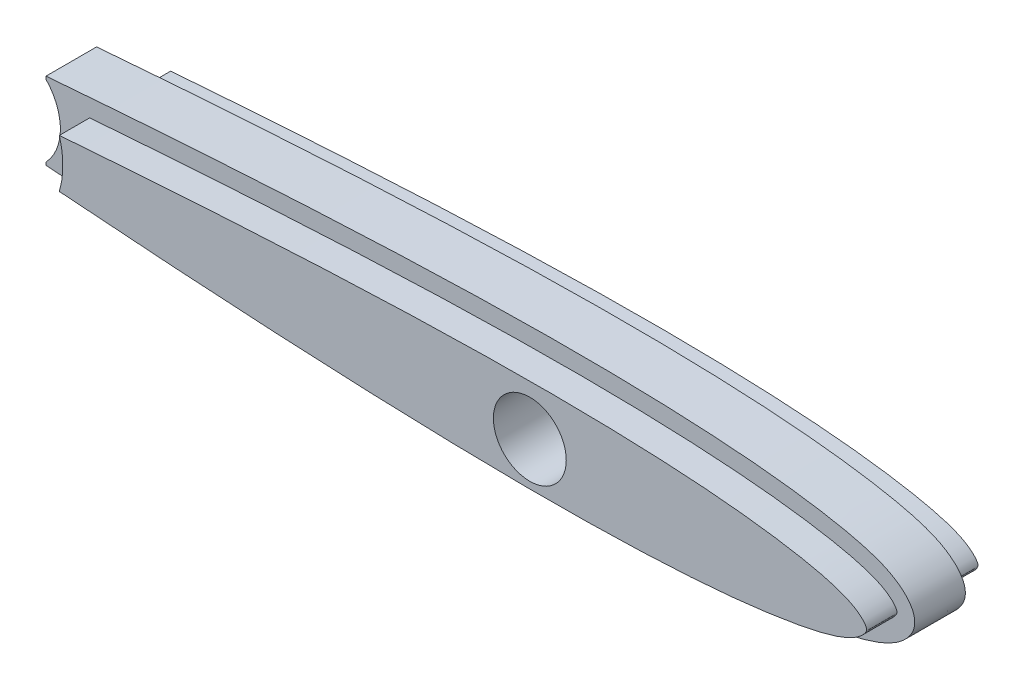
from build123d import *

# Parameters (mm, degrees)
BOSS_EXTRUDE1_DEPTH = 5
SKETCH2_R           = 3.6
CUT_EXTRUDE1_DEPTH  = 5
SKETCH3_R           = 3.6
BOSS_EXTRUDE2_DEPTH = 3
SKETCH4_R           = 3.6
BOSS_EXTRUDE3_DEPTH = 3
CUT_EXTRUDE2_DEPTH  = 3
CUT_EXTRUDE3_DEPTH  = 3


with BuildPart() as part:
    # Sketch1 → Boss-Extrude1 (new body)
    with BuildSketch(Plane.XY):
        with BuildLine():
            Line((-706.793809994, 2.250411623), (-706.793809994, 1.97147251))
            ThreePointArc((-706.793809994, 1.97147251), (-705.375068537, -1.563521785), (-706.793809994, -5.098516081))
            Line((-706.793809994, -5.098516081), (-706.793809994, -5.380220718))
            add(Edge.make_bspline(
                [(-706.793809994, -5.380220718), (-704.176375439, -5.591973248), (-696.788271806, -6.160981291), (-687.004943636, -6.814750309), (-677.443429578, -7.328465039), (-670.265581518, -7.637849476), (-663.080178273, -7.856949826), (-655.886290791, -7.960144603), (-649.882283211, -7.915795095), (-645.073657094, -7.776750842), (-641.466136989, -7.609887873), (-637.854648483, -7.365546758), (-634.840780847, -7.078684435), (-632.429284229, -6.778677485), (-630.622695626, -6.514858819), (-628.812307662, -6.202098358), (-627.300302349, -5.887519285), (-626.075324578, -5.577261081), (-625.144738566, -5.299811117), (-624.201783041, -4.957795864), (-623.396379776, -4.581537473), (-622.748324583, -4.189477017), (-622.264536531, -3.833178944), (-621.888398496, -3.490996777), (-621.573666417, -3.139905403), (-621.335269439, -2.804387975), (-621.152117781, -2.470444907), (-621.013752956, -2.062687894), (-620.948588409, -1.666438774), (-620.978356512, -1.21846251), (-621.102747046, -0.769863534), (-621.289809051, -0.398734203), (-621.521029667, -0.056164767), (-621.841717048, 0.316577074), (-622.213712109, 0.661285055), (-622.697054763, 1.025995289), (-623.34452358, 1.42498987), (-624.150977835, 1.807769279), (-625.095134852, 2.154209602), (-626.026268782, 2.434457764), (-626.945529144, 2.669327648), (-628.160182101, 2.940961031), (-629.669864195, 3.22796374), (-631.478046966, 3.515544636), (-633.887915069, 3.842279402), (-636.903553501, 4.156872173), (-640.515254098, 4.42458971), (-644.124028039, 4.609745533), (-647.73159652, 4.729751391), (-652.534840565, 4.817654121), (-658.5377679, 4.807713582), (-665.728070005, 4.659067049), (-672.910308043, 4.404167014), (-680.085871056, 4.065223292), (-689.644295843, 3.519258278), (-698.545185009, 2.901350773), (-705.054875216, 2.391074048), (-706.793809994, 2.250411623)],
                knots=[0.161071555, 0.161071555, 0.161071555, 0.161071555, 0.197140461, 0.262860095, 0.295719912, 0.328579729, 0.361439545, 0.394299362, 0.427159179, 0.443589088, 0.460018996, 0.476448904, 0.492878813, 0.501093767, 0.509308721, 0.517523675, 0.52573863, 0.529846107, 0.533953584, 0.538061061, 0.542168538, 0.544222277, 0.546276015, 0.548329754, 0.549356623, 0.550383492, 0.551410361, 0.551923796, 0.552437231, 0.552950665, 0.5534641, 0.554490969, 0.555517839, 0.556544708, 0.558598446, 0.560652185, 0.562705924, 0.566813401, 0.570920878, 0.575028355, 0.579135832, 0.583243309, 0.591458263, 0.599673217, 0.607888172, 0.62431808, 0.640747988, 0.657177897, 0.673607805, 0.690037714, 0.722897531, 0.755757347, 0.788617164, 0.821476981, 0.854336798, 0.920056432, 0.944017709, 0.944017709, 0.944017709, 0.944017709], degree=3))
        make_face()
    extrude(amount=BOSS_EXTRUDE1_DEPTH)

    # Sketch2 → Cut-Extrude1 (cut)
    with BuildSketch(Plane(origin=(0, 0, 0), x_dir=(-1, 0, 0), z_dir=(0, 0, -1))):
        with Locations((655.992889877, -1.919458309)):
            Circle(SKETCH2_R)
    extrude(amount=-CUT_EXTRUDE1_DEPTH, mode=Mode.SUBTRACT)

    # Sketch3 → Boss-Extrude2 (add)
    with BuildSketch(Plane.XY.offset(5)):
        with BuildLine():
            ThreePointArc((-702.8119034, -4.189841251), (-702.375068622, -1.564694249), (-702.811144658, 1.060578898))
            add(Edge.make_bspline(
                [(-702.8119034, -4.189841251), (-700.917313824, -4.336241444), (-696.793783217, -4.643411612), (-690.360255168, -5.085057096), (-683.472099639, -5.505971596), (-676.464013183, -5.873438985), (-669.455701438, -6.165615313), (-663.668912094, -6.334400701), (-659.129505656, -6.411939523), (-655.827098123, -6.439457694), (-652.612824651, -6.435613741), (-649.500432858, -6.394237419), (-646.503492978, -6.321608231), (-643.635086194, -6.211922431), (-640.907267874, -6.069173931), (-638.331358127, -5.890035138), (-635.918279427, -5.677537233), (-633.679144814, -5.429819661), (-631.623287424, -5.151604924), (-629.758745754, -4.850065184), (-628.093285087, -4.52655103), (-626.632315737, -4.182183625), (-625.382756266, -3.805365702), (-624.347318876, -3.389117853), (-623.535477719, -2.929845627), (-622.951664887, -2.450264066), (-622.587069704, -2.010708523), (-622.411159705, -1.564660699), (-622.587069704, -1.118612875), (-622.951664887, -0.679057332), (-623.535477719, -0.199475771), (-624.347318876, 0.259796455), (-625.382756266, 0.676044303), (-626.632315737, 1.052862227), (-628.093285087, 1.397229632), (-629.758745754, 1.720743786), (-631.623287424, 2.022283526), (-633.679144814, 2.300498263), (-635.918279427, 2.548215835), (-638.331358127, 2.76071374), (-640.907267874, 2.939852533), (-643.635086194, 3.082601032), (-646.503492978, 3.192286833), (-649.500432858, 3.264916021), (-652.612824651, 3.306292343), (-655.827098123, 3.310136295), (-659.129505656, 3.282618125), (-663.668912094, 3.205079304), (-669.455701437, 3.03629391), (-676.464013186, 2.744117603), (-683.472099631, 2.376650136), (-690.360255198, 1.955735922), (-696.793530026, 1.514106834), (-700.916808032, 1.20695911), (-702.811144658, 1.060578898)],
                knots=[0.127353429, 0.127353429, 0.127353429, 0.127353429, 0.153490017, 0.184226953, 0.216050302, 0.248408155, 0.280749827, 0.312527151, 0.328032777, 0.343195028, 0.357950764, 0.37224227, 0.386006959, 0.3991829, 0.411723018, 0.423576276, 0.434696708, 0.445039635, 0.454559181, 0.463228705, 0.471014913, 0.477890529, 0.483865645, 0.488951694, 0.493207386, 0.496651844, 0.499261497, 0.501068994, 0.502876492, 0.505486145, 0.508930603, 0.513186294, 0.518272343, 0.524247459, 0.531123075, 0.538909284, 0.547578808, 0.557098354, 0.56744128, 0.578561712, 0.59041497, 0.602955088, 0.61613103, 0.629895718, 0.644187224, 0.658942961, 0.674105212, 0.689610838, 0.721388161, 0.753729833, 0.786087687, 0.817911036, 0.848647972, 0.874781071, 0.874781071, 0.874781071, 0.874781071], degree=3))
        make_face()
        with Locations(Location((-655.992889877, -1.919458309, 0), (0, 0, 180))):
            Circle(SKETCH3_R, mode=Mode.SUBTRACT)
    extrude(amount=BOSS_EXTRUDE2_DEPTH)

    # Sketch4 → Boss-Extrude3 (add)
    with BuildSketch(Plane(origin=(0, 0, 0), x_dir=(-1, 0, 0), z_dir=(0, 0, -1))):
        with BuildLine():
            ThreePointArc((702.811144658, 1.060578898), (702.375068622, -1.564694249), (702.8119034, -4.189841251))
            add(Edge.make_bspline(
                [(702.811144658, 1.060578898), (700.916808032, 1.20695911), (696.793530026, 1.514106834), (690.360255198, 1.955735922), (683.472099631, 2.376650136), (676.464013186, 2.744117603), (669.455701437, 3.03629391), (663.668912094, 3.205079304), (659.129505656, 3.282618125), (655.827098123, 3.310136295), (652.612824651, 3.306292343), (649.500432858, 3.264916021), (646.503492978, 3.192286833), (643.635086194, 3.082601032), (640.907267874, 2.939852533), (638.331358127, 2.76071374), (635.918279427, 2.548215835), (633.679144814, 2.300498263), (631.623287424, 2.022283526), (629.758745754, 1.720743786), (628.093285087, 1.397229632), (626.632315737, 1.052862227), (625.382756266, 0.676044303), (624.347318876, 0.259796455), (623.535477719, -0.199475771), (622.951664887, -0.679057332), (622.587069704, -1.118612875), (622.411159705, -1.564660699), (622.587069704, -2.010708523), (622.951664887, -2.450264066), (623.535477719, -2.929845627), (624.347318876, -3.389117853), (625.382756266, -3.805365702), (626.632315737, -4.182183625), (628.093285087, -4.52655103), (629.758745754, -4.850065184), (631.623287424, -5.151604924), (633.679144814, -5.429819661), (635.918279427, -5.677537233), (638.331358127, -5.890035138), (640.907267874, -6.069173931), (643.635086194, -6.211922431), (646.503492978, -6.321608231), (649.500432858, -6.394237419), (652.612824651, -6.435613741), (655.827098123, -6.439457694), (659.129505656, -6.411939523), (663.668912094, -6.334400701), (669.455701438, -6.165615313), (676.464013183, -5.873438985), (683.472099639, -5.505971596), (690.360255168, -5.085057096), (696.793783217, -4.643411612), (700.917313824, -4.336241444), (702.8119034, -4.189841251)],
                knots=[0.127353429, 0.127353429, 0.127353429, 0.127353429, 0.153486527, 0.184223463, 0.216046813, 0.248404666, 0.280746338, 0.312523662, 0.328029288, 0.343191539, 0.357947275, 0.372238781, 0.38600347, 0.399179411, 0.411719529, 0.423572787, 0.434693219, 0.445036146, 0.454555692, 0.463225215, 0.471011424, 0.47788704, 0.483862156, 0.488948205, 0.493203896, 0.496648355, 0.499258008, 0.501065505, 0.502873002, 0.505482655, 0.508927114, 0.513182805, 0.518268854, 0.52424397, 0.531119586, 0.538905795, 0.547575319, 0.557094864, 0.567437791, 0.578558223, 0.590411481, 0.602951599, 0.616127541, 0.629892229, 0.644183735, 0.658939472, 0.674101723, 0.689607348, 0.721384672, 0.753726344, 0.786084197, 0.817907547, 0.848644483, 0.874781071, 0.874781071, 0.874781071, 0.874781071], degree=3))
        make_face()
        with Locations((655.992889877, -1.919458309)):
            Circle(SKETCH4_R, mode=Mode.SUBTRACT)
    extrude(amount=BOSS_EXTRUDE3_DEPTH)

    # Sketch5 → Cut-Extrude2 (cut)
    with BuildSketch(Plane(origin=(0, 0, -3), x_dir=(-1, 0, 0), z_dir=(0, 0, -1))):
        with BuildLine():
            Line((706.793809994, -5.380220718), (706.793809994, -5.098516081))
            ThreePointArc((706.793809994, -5.098516081), (705.375068537, -1.563521785), (706.793809994, 1.97147251))
            Line((706.793809994, 1.97147251), (706.793809994, 2.250411623))
            add(Edge.make_bspline(
                [(706.793809994, 2.250411623), (705.054875216, 2.391074048), (698.545185009, 2.901350773), (689.644295843, 3.519258278), (680.085871056, 4.065223292), (672.910308043, 4.404167014), (665.728070005, 4.659067049), (658.5377679, 4.807713582), (652.534840565, 4.817654121), (647.73159652, 4.729751391), (644.124028039, 4.609745533), (640.515254098, 4.42458971), (636.903553501, 4.156872173), (633.887915069, 3.842279402), (631.478046966, 3.515544636), (629.669864195, 3.22796374), (628.160182101, 2.940961031), (626.945529144, 2.669327648), (626.026268782, 2.434457764), (625.095134852, 2.154209602), (624.150977835, 1.807769279), (623.34452358, 1.42498987), (622.697054763, 1.025995289), (622.213712109, 0.661285055), (621.841717048, 0.316577074), (621.521029667, -0.056164767), (621.289809051, -0.398734203), (621.102747046, -0.769863534), (620.978356512, -1.21846251), (620.948588409, -1.666438774), (621.013752956, -2.062687894), (621.152117781, -2.470444907), (621.335269439, -2.804387975), (621.573666417, -3.139905403), (621.888398496, -3.490996777), (622.264536531, -3.833178944), (622.748324583, -4.189477017), (623.396379776, -4.581537473), (624.201783041, -4.957795864), (625.144738566, -5.299811117), (626.075324578, -5.577261081), (627.300302349, -5.887519285), (628.812307662, -6.202098358), (630.622695626, -6.514858819), (632.429284229, -6.778677485), (634.840780847, -7.078684435), (637.854648483, -7.365546758), (641.466136989, -7.609887873), (645.073657094, -7.776750842), (649.882283211, -7.915795095), (655.886290791, -7.960144603), (663.080178273, -7.856949826), (670.265581518, -7.637849476), (677.443429578, -7.328465039), (687.004943636, -6.814750309), (696.788271806, -6.160981291), (704.176375439, -5.591973248), (706.793809994, -5.380220718)],
                knots=[0.161071555, 0.161071555, 0.161071555, 0.161071555, 0.185032833, 0.250752466, 0.283612283, 0.3164721, 0.349331917, 0.382191734, 0.415051551, 0.431481459, 0.447911367, 0.464341276, 0.480771184, 0.497201093, 0.505416047, 0.513631001, 0.521845955, 0.525953432, 0.530060909, 0.534168387, 0.538275864, 0.542383341, 0.544437079, 0.546490818, 0.548544556, 0.549571426, 0.550598295, 0.551625164, 0.552138599, 0.552652033, 0.553165468, 0.553678903, 0.554705772, 0.555732641, 0.556759511, 0.558813249, 0.560866988, 0.562920726, 0.567028203, 0.57113568, 0.575243158, 0.579350635, 0.587565589, 0.595780543, 0.603995497, 0.612210451, 0.62864036, 0.645070268, 0.661500177, 0.677930085, 0.710789902, 0.743649719, 0.776509536, 0.809369352, 0.842229169, 0.907948803, 0.944017709, 0.944017709, 0.944017709, 0.944017709], degree=3))
        make_face()
        with BuildLine():
            ThreePointArc((702.476574341, 0.835638079), (702.125068618, -1.564683634), (702.477241241, -3.96490759))
            add(Edge.make_bspline(
                [(702.476574341, 0.835638079), (695.714535449, 1.356072094), (688.949961769, 1.815163268), (678.79777695, 2.374949995), (675.412797043, 2.539322357), (668.640430249, 2.809817236), (665.253088699, 2.917036954), (658.475029247, 3.049767371), (655.084422916, 3.077978134), (648.297874843, 3.005280729), (644.903780303, 2.911161539), (639.823261567, 2.621026958), (638.131156929, 2.498644663), (634.751026413, 2.179176654), (633.063883995, 1.980352596), (630.54773716, 1.597738211), (629.711156544, 1.456110292), (628.04471228, 1.12852618), (627.213928507, 0.945337391), (625.990923587, 0.598825966), (625.587033549, 0.470662913), (624.792169879, 0.171059849), (624.398849623, -0.002208811), (623.84868765, -0.317733693), (623.671601998, -0.432604061), (623.334620991, -0.688792854), (623.172862077, -0.830743248), (622.955872398, -1.07057219), (622.88861472, -1.155822239), (622.80403255, -1.293117197), (622.778134602, -1.34025964), (622.734754325, -1.439593137), (622.716961027, -1.491460275), (622.708984643, -1.599207916), (622.722811035, -1.652681606), (622.760295399, -1.752812358), (622.784553347, -1.800387473), (622.864781012, -1.939747562), (622.928834512, -2.025122122), (623.136927835, -2.264396885), (623.296221065, -2.407714337), (623.629819046, -2.667802161), (623.805168654, -2.784110208), (624.349798724, -3.103185114), (624.738923374, -3.277604015), (625.523218508, -3.578264794), (625.921283941, -3.706498383), (626.724233873, -3.937503764), (627.129107318, -4.04031683), (628.350133671, -4.32483651), (629.17250484, -4.484968507), (630.824124238, -4.772595978), (631.651216318, -4.898798597), (634.135167715, -5.240668183), (635.794871243, -5.417275198), (639.119258997, -5.702088646), (640.783835708, -5.811771573), (645.782742589, -6.069727403), (649.123210603, -6.152095498), (655.806475634, -6.204123024), (659.145536164, -6.170399485), (665.820511732, -6.029894773), (669.156334021, -5.920959387), (675.82566545, -5.649363056), (679.159127776, -5.485614816), (689.156758801, -4.930359952), (695.818294647, -4.47740886), (702.477241241, -3.96490759)],
                knots=[0, 0, 0, 0, 0.125, 0.125, 0.1875, 0.1875, 0.25, 0.25, 0.3125, 0.3125, 0.375, 0.375, 0.40625, 0.40625, 0.4375, 0.4375, 0.453125, 0.453125, 0.46875, 0.46875, 0.4765625, 0.4765625, 0.484375, 0.484375, 0.48828125, 0.48828125, 0.4921875, 0.4921875, 0.494140625, 0.494140625, 0.495117188, 0.495117188, 0.49609375, 0.49609375, 0.497070313, 0.497070313, 0.498046875, 0.498046875, 0.5, 0.5, 0.50390625, 0.50390625, 0.5078125, 0.5078125, 0.515625, 0.515625, 0.5234375, 0.5234375, 0.53125, 0.53125, 0.546875, 0.546875, 0.5625, 0.5625, 0.59375, 0.59375, 0.625, 0.625, 0.6875, 0.6875, 0.75, 0.75, 0.8125, 0.8125, 0.875, 0.875, 1, 1, 1, 1], degree=3))
        make_face(mode=Mode.SUBTRACT)
    extrude(amount=-CUT_EXTRUDE2_DEPTH, mode=Mode.SUBTRACT)

    # Sketch6 → Cut-Extrude3 (cut)
    with BuildSketch(Plane.XY.offset(8)):
        with BuildLine():
            Line((-706.793809994, -5.098516081), (-706.793809994, -5.380220718))
            add(Edge.make_bspline(
                [(-706.793809994, -5.380220718), (-704.176375439, -5.591973248), (-696.788271806, -6.160981291), (-687.004943636, -6.814750309), (-677.443429578, -7.328465039), (-670.265581518, -7.637849476), (-663.080178273, -7.856949826), (-655.886290791, -7.960144603), (-649.882283211, -7.915795095), (-645.073657094, -7.776750842), (-641.466136989, -7.609887873), (-637.854648483, -7.365546758), (-634.840780847, -7.078684435), (-632.429284229, -6.778677485), (-630.622695626, -6.514858819), (-628.812307662, -6.202098358), (-627.300302349, -5.887519285), (-626.075324578, -5.577261081), (-625.144738566, -5.299811117), (-624.201783041, -4.957795864), (-623.396379776, -4.581537473), (-622.748324583, -4.189477017), (-622.264536531, -3.833178944), (-621.888398496, -3.490996777), (-621.573666417, -3.139905403), (-621.335269439, -2.804387975), (-621.152117781, -2.470444907), (-621.013752956, -2.062687894), (-620.948588409, -1.666438774), (-620.978356512, -1.21846251), (-621.102747046, -0.769863534), (-621.289809051, -0.398734203), (-621.521029667, -0.056164767), (-621.841717048, 0.316577074), (-622.213712109, 0.661285055), (-622.697054763, 1.025995289), (-623.34452358, 1.42498987), (-624.150977835, 1.807769279), (-625.095134852, 2.154209602), (-626.026268782, 2.434457764), (-626.945529144, 2.669327648), (-628.160182101, 2.940961031), (-629.669864195, 3.22796374), (-631.478046966, 3.515544636), (-633.887915069, 3.842279402), (-636.903553501, 4.156872173), (-640.515254098, 4.42458971), (-644.124028039, 4.609745533), (-647.73159652, 4.729751391), (-652.534840565, 4.817654121), (-658.5377679, 4.807713582), (-665.728070005, 4.659067049), (-672.910308043, 4.404167014), (-680.085871056, 4.065223292), (-689.644295843, 3.519258278), (-698.545185009, 2.901350773), (-705.054875216, 2.391074048), (-706.793809994, 2.250411623)],
                knots=[0.161071555, 0.161071555, 0.161071555, 0.161071555, 0.197140461, 0.262860095, 0.295719912, 0.328579729, 0.361439545, 0.394299362, 0.427159179, 0.443589088, 0.460018996, 0.476448904, 0.492878813, 0.501093767, 0.509308721, 0.517523675, 0.52573863, 0.529846107, 0.533953584, 0.538061061, 0.542168538, 0.544222277, 0.546276015, 0.548329754, 0.549356623, 0.550383492, 0.551410361, 0.551923796, 0.552437231, 0.552950665, 0.5534641, 0.554490969, 0.555517839, 0.556544708, 0.558598446, 0.560652185, 0.562705924, 0.566813401, 0.570920878, 0.575028355, 0.579135832, 0.583243309, 0.591458263, 0.599673217, 0.607888172, 0.62431808, 0.640747988, 0.657177897, 0.673607805, 0.690037714, 0.722897531, 0.755757347, 0.788617164, 0.821476981, 0.854336798, 0.920056432, 0.944017709, 0.944017709, 0.944017709, 0.944017709], degree=3))
            Line((-706.793809994, 2.250411623), (-706.793809994, 1.97147251))
            ThreePointArc((-706.793809994, 1.97147251), (-705.375068537, -1.563521785), (-706.793809994, -5.098516081))
        make_face()
        with BuildLine():
            ThreePointArc((-702.477241241, -3.96490759), (-702.125068618, -1.564683634), (-702.476574341, 0.835638079))
            add(Edge.make_bspline(
                [(-702.477241241, -3.96490759), (-695.818294647, -4.47740886), (-689.156758801, -4.930359952), (-679.159127776, -5.485614816), (-675.82566545, -5.649363056), (-669.156334021, -5.920959387), (-665.820511732, -6.029894773), (-659.145536164, -6.170399485), (-655.806475634, -6.204123024), (-649.123210603, -6.152095498), (-645.782742589, -6.069727403), (-640.783835708, -5.811771573), (-639.119258997, -5.702088646), (-635.794871243, -5.417275198), (-634.135167715, -5.240668183), (-631.651216318, -4.898798597), (-630.824124238, -4.772595978), (-629.17250484, -4.484968507), (-628.350133671, -4.32483651), (-627.129107318, -4.04031683), (-626.724233873, -3.937503764), (-625.921283941, -3.706498383), (-625.523218508, -3.578264794), (-624.738923374, -3.277604015), (-624.349798724, -3.103185114), (-623.805168654, -2.784110208), (-623.629819046, -2.667802161), (-623.296221065, -2.407714337), (-623.136927835, -2.264396885), (-622.928834512, -2.025122122), (-622.864781012, -1.939747562), (-622.784553347, -1.800387473), (-622.760295399, -1.752812358), (-622.722811035, -1.652681606), (-622.708984643, -1.599207916), (-622.716961027, -1.491460275), (-622.734754325, -1.439593137), (-622.778134602, -1.34025964), (-622.80403255, -1.293117197), (-622.88861472, -1.155822239), (-622.955872398, -1.07057219), (-623.172862077, -0.830743248), (-623.334620991, -0.688792854), (-623.671601998, -0.432604061), (-623.84868765, -0.317733693), (-624.398849623, -0.002208811), (-624.792169879, 0.171059849), (-625.587033549, 0.470662913), (-625.990923587, 0.598825966), (-627.213928507, 0.945337391), (-628.04471228, 1.12852618), (-629.711156544, 1.456110292), (-630.54773716, 1.597738211), (-633.063883995, 1.980352596), (-634.751026413, 2.179176654), (-638.131156929, 2.498644663), (-639.823261567, 2.621026958), (-644.903780303, 2.911161539), (-648.297874843, 3.005280729), (-655.084422916, 3.077978134), (-658.475029247, 3.049767371), (-665.253088699, 2.917036954), (-668.640430249, 2.809817236), (-675.412797043, 2.539322357), (-678.79777695, 2.374949995), (-688.949961769, 1.815163268), (-695.714535449, 1.356072094), (-702.476574341, 0.835638079)],
                knots=[0, 0, 0, 0, 0.125, 0.125, 0.1875, 0.1875, 0.25, 0.25, 0.3125, 0.3125, 0.375, 0.375, 0.40625, 0.40625, 0.4375, 0.4375, 0.453125, 0.453125, 0.46875, 0.46875, 0.4765625, 0.4765625, 0.484375, 0.484375, 0.4921875, 0.4921875, 0.49609375, 0.49609375, 0.5, 0.5, 0.501953125, 0.501953125, 0.502929687, 0.502929687, 0.50390625, 0.50390625, 0.504882812, 0.504882812, 0.505859375, 0.505859375, 0.5078125, 0.5078125, 0.51171875, 0.51171875, 0.515625, 0.515625, 0.5234375, 0.5234375, 0.53125, 0.53125, 0.546875, 0.546875, 0.5625, 0.5625, 0.59375, 0.59375, 0.625, 0.625, 0.6875, 0.6875, 0.75, 0.75, 0.8125, 0.8125, 0.875, 0.875, 1, 1, 1, 1], degree=3))
        make_face(mode=Mode.SUBTRACT)
    extrude(amount=-CUT_EXTRUDE3_DEPTH, mode=Mode.SUBTRACT)


solid = part.part
